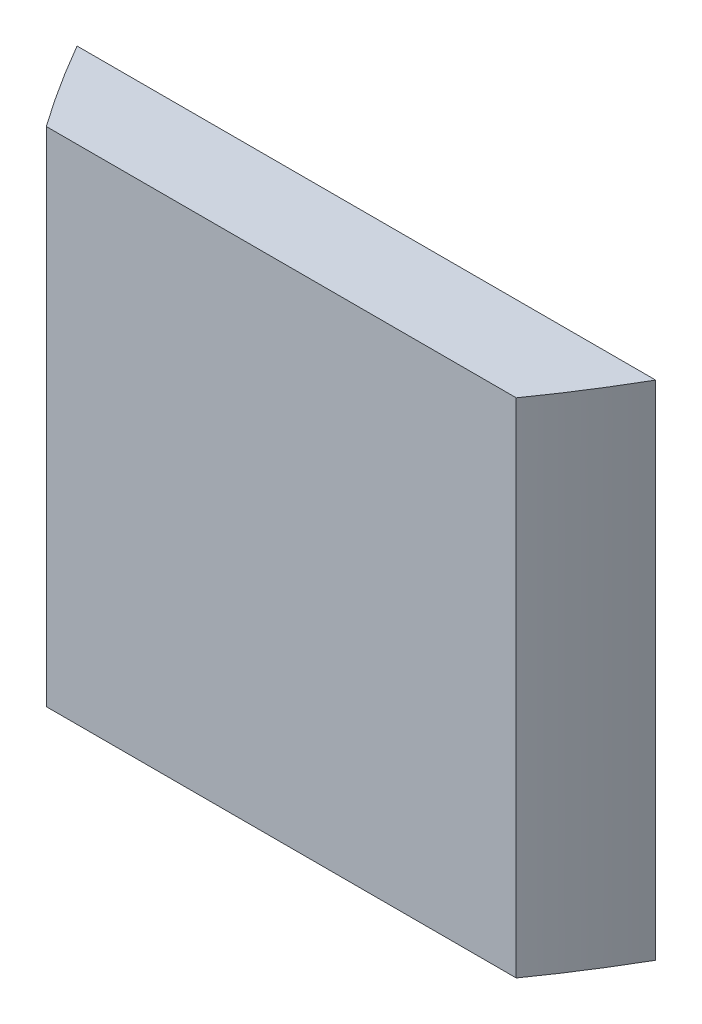
from build123d import *

# Parameters (mm, degrees)
BOSS_EXTRUDE1_DEPTH = 300
SKETCH2_W           = 448.898553089
SKETCH2_H           = 98.376583204
CUT_EXTRUDE1_DEPTH  = 350
SKETCH3_W           = 441.3036111
SKETCH3_H           = 137.787771029
CUT_EXTRUDE2_DEPTH  = 350


with BuildPart() as part:
    # Sketch1 → Boss-Extrude1 (new body)
    with BuildSketch(Plane(origin=(0, 0, 0), x_dir=(1, 0, 0), z_dir=(0, 1, 0))):
        with BuildLine():
            Line((-200, 1e-09), (200, 1e-09))
            add(Edge.make_bspline(
                [(-200, 1e-09), (0, -400.000000001), (200, 1e-09)],
                knots=[0.056028396, 0.056028396, 0.056028396, 0.943971604, 0.943971604, 0.943971604], degree=2))
        make_face()
    extrude(amount=BOSS_EXTRUDE1_DEPTH)

    # Sketch2 → Cut-Extrude1 (cut)
    with BuildSketch(Plane(origin=(0, 300, 0), x_dir=(1, 0, 0), z_dir=(0, 1, 0))):
        with Locations((1.772551048, -1.611708397)):
            Rectangle(SKETCH2_W, SKETCH2_H)
    extrude(amount=-CUT_EXTRUDE1_DEPTH, mode=Mode.SUBTRACT)

    # Sketch3 → Cut-Extrude2 (cut)
    with BuildSketch(Plane(origin=(0, 300, 0), x_dir=(1, 0, 0), z_dir=(0, 1, 0))):
        with Locations((-0.765487617, -170.493885514)):
            Rectangle(SKETCH3_W, SKETCH3_H)
    extrude(amount=-CUT_EXTRUDE2_DEPTH, mode=Mode.SUBTRACT)


solid = part.part
